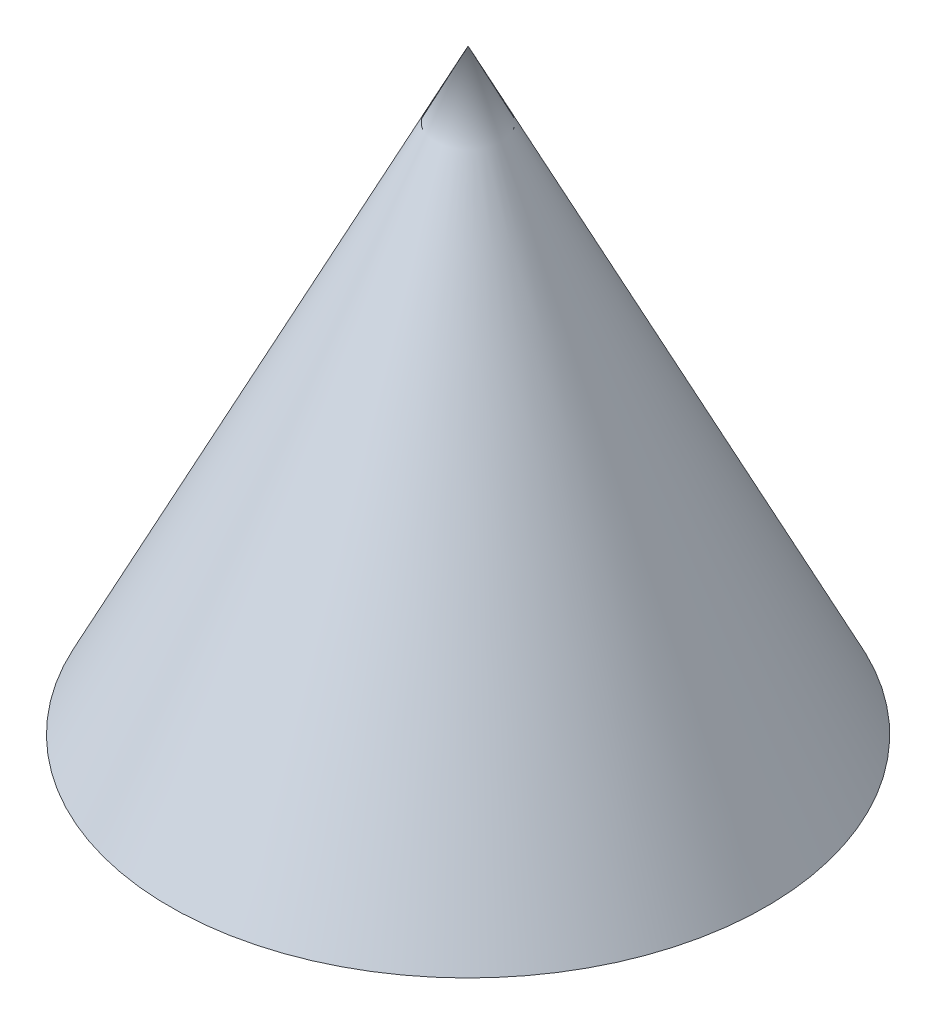
from build123d import *


with BuildPart() as part:
    # Sketch1 → Revolve1 (revolve)
    with BuildSketch(Plane.XY, mode=Mode.PRIVATE) as revolve1_sk:
        Polygon((0, 0), (25, 0), (0, 50), align=None)
    revolve(revolve1_sk.sketch.rotate(Axis((0, 0, 0), (0, 1, 0)), 90), axis=Axis((0, 0, 0), (0, 1, 0)))  # turned: the seam where the file's is


solid = part.part
